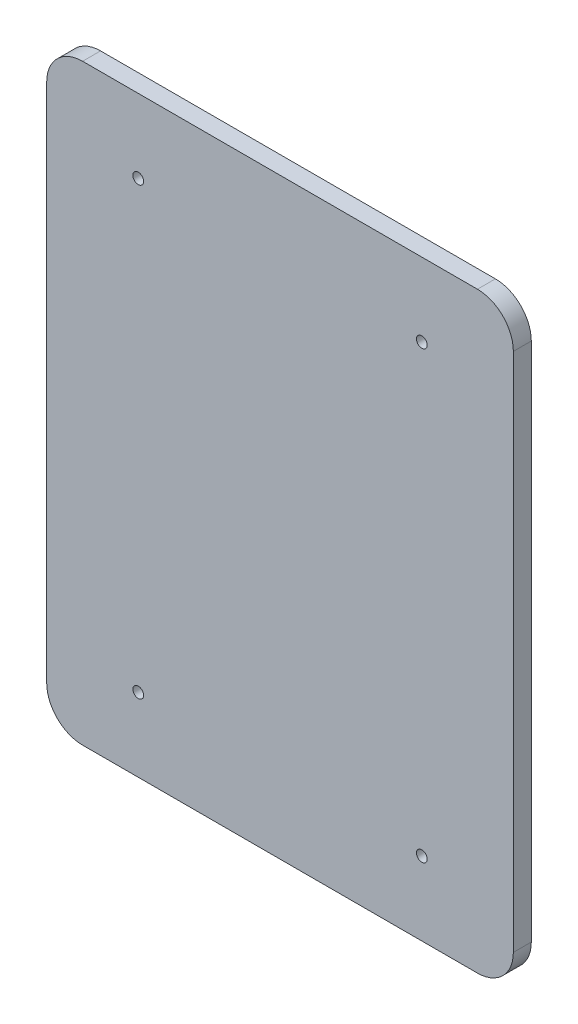
from build123d import *

# Parameters (mm, degrees)
RESSALTO_EXTRUS_O1_DEPTH = 5
ESBO_O2_R                = 1.5
CORTE_EXTRUS_O1_DEPTH    = 5


with BuildPart() as part:
    # Esboço1 → Ressalto-extrusão1 (new body)
    with BuildSketch(Plane.XY):
        with BuildLine():
            Line((-49.217119449, -36.393854661), (60.782880551, -36.393854661))
            ThreePointArc((60.782880551, -36.393854661), (67.853948363, -33.464922473), (70.782880551, -26.393854661))
            Line((70.782880551, -26.393854661), (70.782880551, 118.606145339))
            ThreePointArc((70.782880551, 118.606145339), (67.853948363, 125.67721315), (60.782880551, 128.606145339))
            Line((60.782880551, 128.606145339), (-49.217119449, 128.606145339))
            ThreePointArc((-49.217119449, 128.606145339), (-56.288187261, 125.67721315), (-59.217119449, 118.606145339))
            Line((-59.217119449, 118.606145339), (-59.217119449, -26.393854661))
            ThreePointArc((-59.217119449, -26.393854661), (-56.288187261, -33.464922473), (-49.217119449, -36.393854661))
        make_face()
    extrude(amount=RESSALTO_EXTRUS_O1_DEPTH)

    # Esboço2 → Corte-extrusão1 (cut)
    with BuildSketch(Plane(origin=(0, 0, 0), x_dir=(-1, 0, 0), z_dir=(0, 0, -1))):
        with Locations((33.717119449, -15.893854661)):
            Circle(ESBO_O2_R)
        with Locations((33.717119449, 108.106145339)):
            Circle(ESBO_O2_R)
        with Locations((-45.282880551, -15.893854661)):
            Circle(ESBO_O2_R)
        with Locations((-45.282880551, 108.106145339)):
            Circle(ESBO_O2_R)
    extrude(amount=-CORTE_EXTRUS_O1_DEPTH, mode=Mode.SUBTRACT)


solid = part.part
